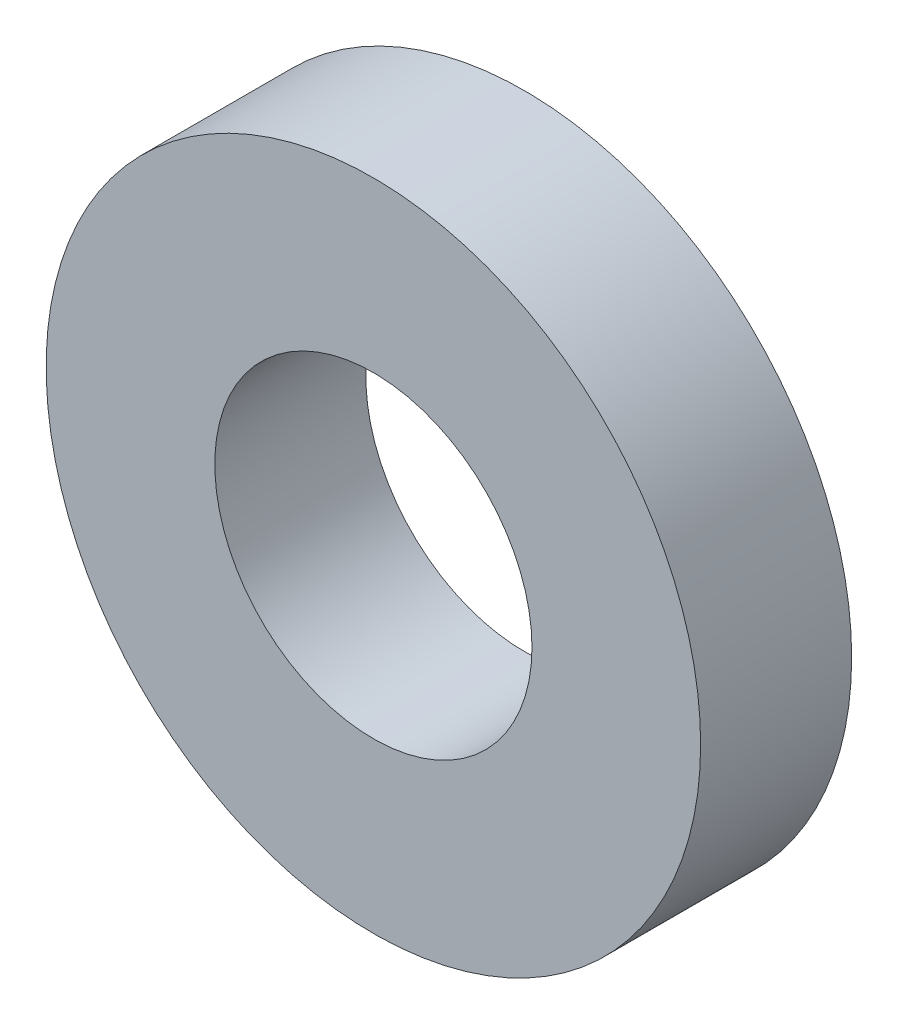
from build123d import *

# Parameters (mm, degrees)
SKETCH1_R      = 6.5
SKETCH1_R_2    = 3.15
EXTRUDE1_DEPTH = 1.5


with BuildPart() as part:
    # Sketch1 → Extrude1 (new body, symmetric)
    with BuildSketch(Plane.XY):
        Circle(SKETCH1_R)
        Circle(SKETCH1_R_2, mode=Mode.SUBTRACT)
    extrude(amount=EXTRUDE1_DEPTH, both=True)


solid = part.part
